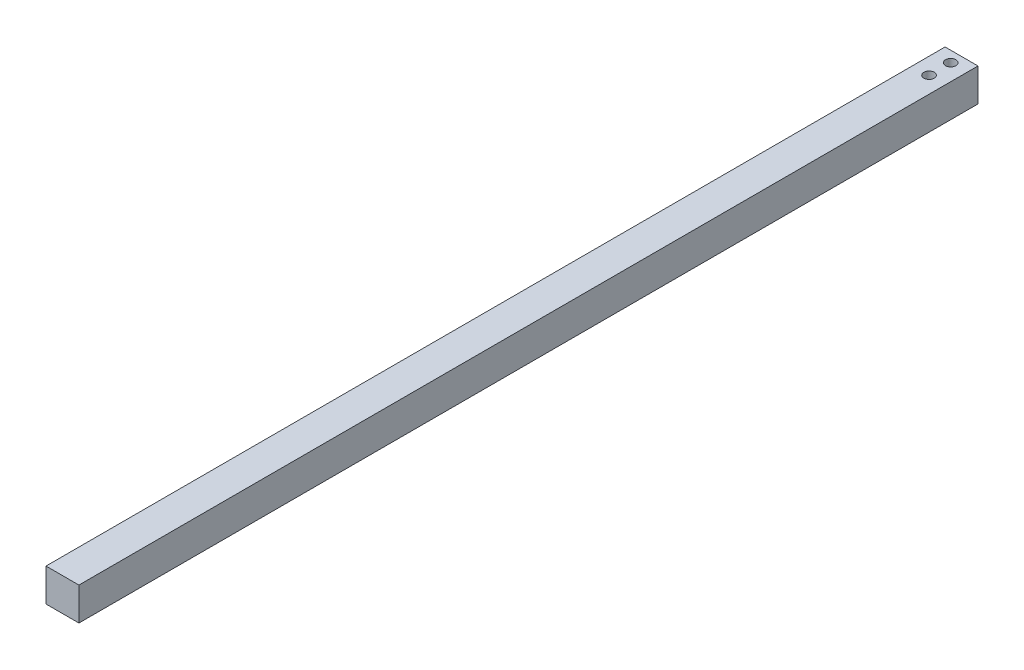
from build123d import *

# Parameters (mm, degrees)
SKETCH1_W               = 19
SKETCH1_H               = 19
BOSS_EXTRUDE1_DEPTH     = 519
CUT_EXTRUDE1_DEPTH      = 9
CUT_EXTRUDE2_DEPTH      = 1
CUT_EXTRUDE2_DEPTH_BACK = 20


with BuildPart() as part:
    # Sketch1 → Boss-Extrude1 (new body)
    with BuildSketch(Plane.XY):
        Rectangle(SKETCH1_W, SKETCH1_H)
    extrude(amount=BOSS_EXTRUDE1_DEPTH)

    # Sketch2 → Cut-Extrude1 (cut)
    with BuildSketch(Plane.XZ.offset(9.5)):
        with BuildLine():
            ThreePointArc((-4, 515.25), (-6, 517.25), (-8, 515.25))
            Line((-8, 515.25), (-4, 515.25))
        make_face()
        with BuildLine():
            Line((-4, 515.25), (-8, 515.25))
            ThreePointArc((-8, 515.25), (-6, 513.25), (-4, 515.25))
        make_face()
        with BuildLine():
            ThreePointArc((8, 515.25), (6, 517.25), (4, 515.25))
            Line((4, 515.25), (6, 515.25))
            Line((6, 515.25), (8, 515.25))
        make_face()
        with BuildLine():
            Line((6, 515.25), (4, 515.25))
            ThreePointArc((4, 515.25), (6, 513.25), (8, 515.25))
            Line((8, 515.25), (6, 515.25))
        make_face()
    extrude(amount=-CUT_EXTRUDE1_DEPTH, mode=Mode.SUBTRACT)

    # Sketch3 → Cut-Extrude2 (cut, two sides)
    with BuildSketch(Plane(origin=(0, 9.5, 0), x_dir=(1, 0, 0), z_dir=(0, 1, 0))) as cut_extrude2_sk:
        with BuildLine():
            ThreePointArc((3, -18.75), (2.121320344, -16.628679656), (0, -15.75))
            Line((0, -15.75), (0, -21.75))
            ThreePointArc((0, -21.75), (2.121320344, -20.871320344), (3, -18.75))
        make_face()
        with BuildLine():
            Line((0, -21.75), (0, -15.75))
            ThreePointArc((0, -15.75), (-3, -18.75), (0, -21.75))
        make_face()
        with BuildLine():
            ThreePointArc((3, -6.25), (2.121320344, -4.128679656), (0, -3.25))
            Line((0, -3.25), (0, -9.25))
            ThreePointArc((0, -9.25), (2.121320344, -8.371320344), (3, -6.25))
        make_face()
        with BuildLine():
            Line((0, -9.25), (0, -3.25))
            ThreePointArc((0, -3.25), (-3, -6.25), (0, -9.25))
        make_face()
    extrude(amount=CUT_EXTRUDE2_DEPTH, mode=Mode.SUBTRACT)
    extrude(cut_extrude2_sk.sketch, amount=-CUT_EXTRUDE2_DEPTH_BACK, mode=Mode.SUBTRACT)


solid = part.part
